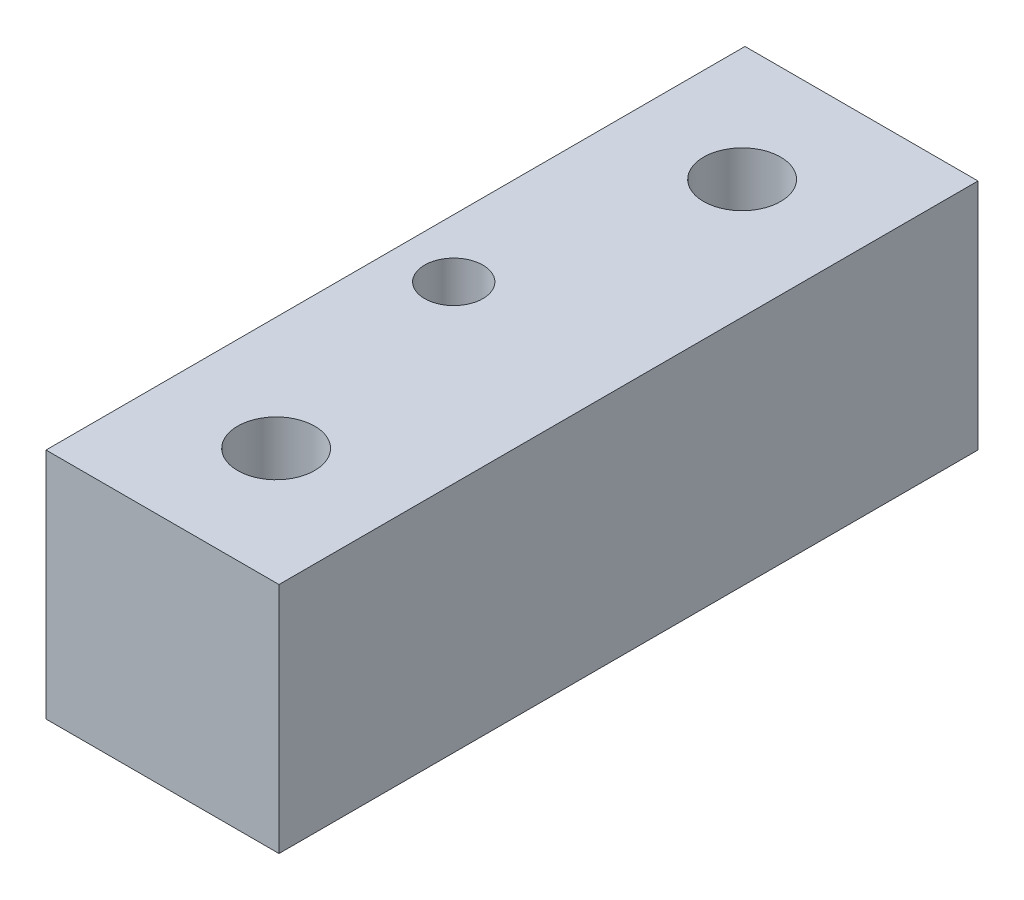
from build123d import *

# Parameters (mm, degrees)
SKETCH1_W                    = 12.7
SKETCH1_H                    = 12.7
BOSS_EXTRUDE1_DEPTH          = 38.1
TAP_DRILL_FOR_M5X0_8_TAP1_D  = 4.2
F_1_8_0_125_DIAMETER_HOLE1_D = 3.175


with BuildPart() as part:
    # Sketch1 → Boss-Extrude1 (new body)
    with BuildSketch(Plane.XY):
        with Locations((6.35, 6.35)):
            Rectangle(SKETCH1_W, SKETCH1_H)
    extrude(amount=BOSS_EXTRUDE1_DEPTH)

    # Tap Drill for M5x0.8 Tap1 (through all)
    with Locations(Plane(origin=(0, 12.7, 0), x_dir=(1, 0, 0), z_dir=(0, 1, 0))):
        with Locations((6.193295447, -6.35), (6.193295447, -31.75)):
            Hole(TAP_DRILL_FOR_M5X0_8_TAP1_D / 2)

    # 1/8 (0.125) Diameter Hole1 (through all)
    with Locations(Plane(origin=(0, 12.7, 0), x_dir=(1, 0, 0), z_dir=(0, 1, 0))):
        with Locations((3.175, -19.05)):
            Hole(F_1_8_0_125_DIAMETER_HOLE1_D / 2)


solid = part.part
